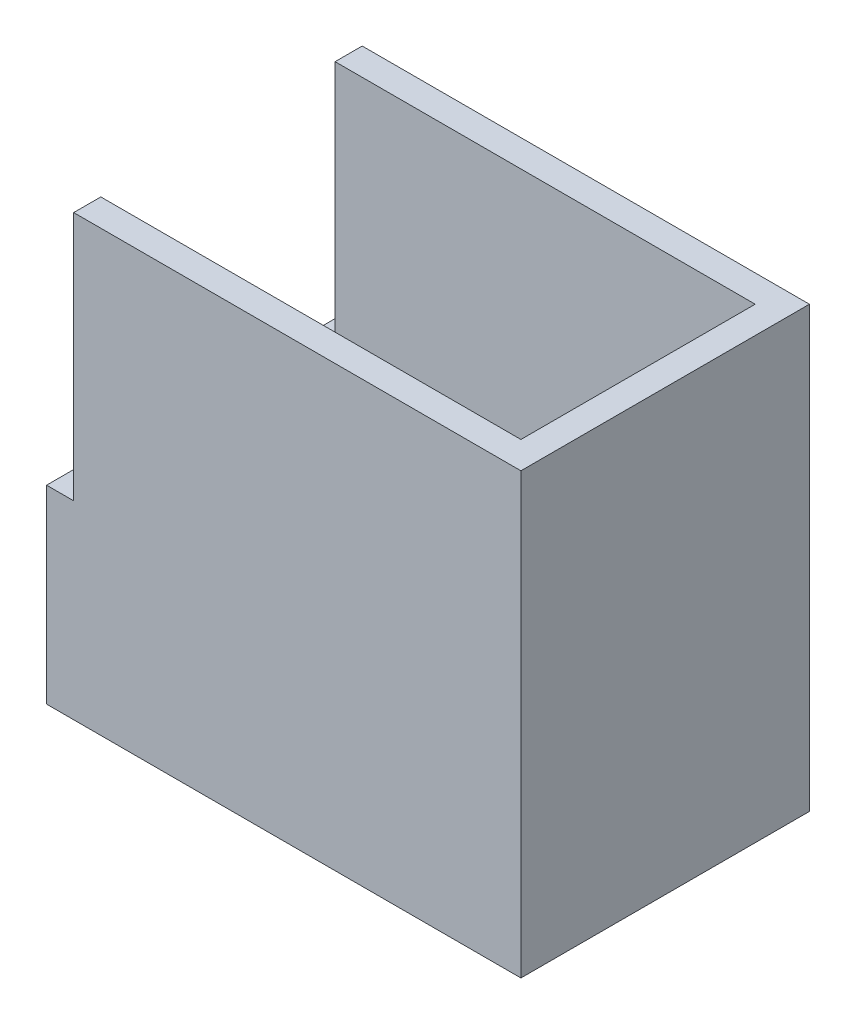
from build123d import *

# Parameters (mm, degrees)
SKETCH_13_W         = 26.24
SKETCH_13_H         = 15.96
SKETCH_13_W_2       = 23.24
SKETCH_13_H_2       = 12.96
EXTRUDE_1_DEPTH     = 22.8
SKETCH_13_3_W       = 26.24
SKETCH_13_3_H       = 15.96
SKETCH_13_3_W_2     = 23.24
SKETCH_13_3_H_2     = 12.96
SKETCH_13_3_W_3     = 18
SKETCH_13_3_W_4     = 1.92
EXTRUDE_2_DEPTH     = 1.5
CUT_EXTRUDE_4_DEPTH = 1.5


with BuildPart() as part:
    # 草图13 → 凸台-拉伸1 (new body)
    with BuildSketch(Plane(origin=(0, 0, 0), x_dir=(1, 0, 0), z_dir=(0, 1, 0))):
        Rectangle(SKETCH_13_W, SKETCH_13_H)
        Rectangle(SKETCH_13_W_2, SKETCH_13_H_2, mode=Mode.SUBTRACT)
    extrude(amount=EXTRUDE_1_DEPTH)

    # 草图13<3> → 凸台-拉伸2 (add)
    with BuildSketch(Plane(origin=(0, 0, 0), x_dir=(1, 0, 0), z_dir=(0, 1, 0))):
        Rectangle(SKETCH_13_3_W, SKETCH_13_3_H)
        Rectangle(SKETCH_13_3_W_2, SKETCH_13_3_H_2, mode=Mode.SUBTRACT)
        with Locations((2.62, 0)):
            Rectangle(SKETCH_13_3_W_3, SKETCH_13_3_H_2)
        with Locations((-10.66, 0)):
            Rectangle(SKETCH_13_3_W_4, SKETCH_13_3_H_2)
    extrude(amount=-EXTRUDE_2_DEPTH)

    # 草图15 → 切除-拉伸4 (cut)
    with BuildSketch(Plane.ZY.offset(13.12)):
        with BuildLine():
            ThreePointArc((-1.600781059, 8.99), (-1.015504801, 8.08951932), (0, 7.74))
            ThreePointArc((0, 7.74), (1.015504801, 8.08951932), (1.600781059, 8.99))
            Line((1.600781059, 8.99), (-1.600781059, 8.99))
        make_face()
        with BuildLine():
            ThreePointArc((1.65, 9.39), (-0.201508377, 11.027649039), (-1.600781059, 8.99))
            Line((-1.600781059, 8.99), (1.600781059, 8.99))
            ThreePointArc((1.600781059, 8.99), (1.637649039, 9.188491623), (1.65, 9.39))
        make_face()
        with BuildLine():
            Line((-7.98, 22.8), (-7.98, 8.99))
            Line((-7.98, 8.99), (-1.600781059, 8.99))
            ThreePointArc((-1.600781059, 8.99), (-0.201508377, 11.027649039), (1.65, 9.39))
            ThreePointArc((1.65, 9.39), (1.637649039, 9.188491623), (1.600781059, 8.99))
            Line((1.600781059, 8.99), (7.98, 8.99))
            Line((7.98, 8.99), (7.98, 22.8))
            Line((7.98, 22.8), (-7.98, 22.8))
        make_face()
    extrude(amount=-CUT_EXTRUDE_4_DEPTH, mode=Mode.SUBTRACT)


solid = part.part
